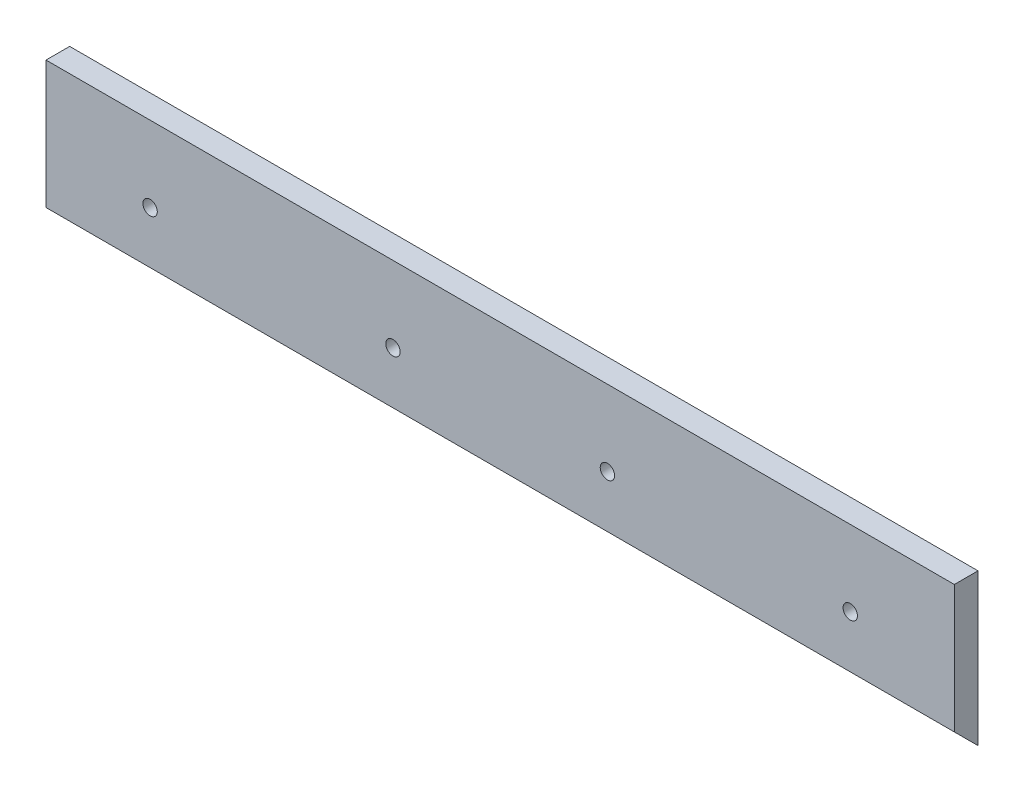
from build123d import *

# Parameters (mm, degrees)
SKETCH1_W               = 609.6
SKETCH1_H               = 101.6
BOSS_EXTRUDE1_DEPTH     = 7.9375
CUT_EXTRUDE2_DEPTH      = 612.764500365
CUT_EXTRUDE2_DEPTH_BACK = 612.764500365
CUT_EXTRUDE3_DEPTH      = 310.411854371
CUT_EXTRUDE3_DEPTH_BACK = 310.411854371
SKETCH4_R               = 4.826
SKETCH4_3_R             = 13.1826
SKETCH4_3_R_2           = 4.826
CUT_EXTRUDE4_DEPTH      = 8.128


with BuildPart() as part:
    # Sketch1 → Boss-Extrude1 (new, symmetric)
    with BuildSketch(Plane.XY):
        Rectangle(SKETCH1_W, SKETCH1_H)
    extrude(amount=BOSS_EXTRUDE1_DEPTH, both=True)

    # Sketch3 → Cut-Extrude2 (cut, two sides: drawn at the far end of the back side and taken through both)
    with BuildSketch(Plane(origin=(304.8, 0, 0), x_dir=(0, 0, -1), z_dir=(1, 0, 0)).offset(-CUT_EXTRUDE2_DEPTH_BACK)):
        Polygon((7.9375, -50.8), (-7.9375, -34.925), (-7.9375, -50.8), align=None)
    extrude(amount=CUT_EXTRUDE2_DEPTH + CUT_EXTRUDE2_DEPTH_BACK, mode=Mode.SUBTRACT)

    # Sketch4 → Cut-Extrude3 (cut, two sides: drawn at the far end of the back side and taken through both)
    with BuildSketch(Plane(origin=(0, 0, -7.9375), x_dir=(-1, 0, 0), z_dir=(0, 0, -1)).offset(-CUT_EXTRUDE3_DEPTH_BACK)):
        with Locations((-234.95, 0)):
            Circle(SKETCH4_R)
        with Locations((-71.966666709, 0)):
            Circle(SKETCH4_R)
        with Locations((71.966666709, 0)):
            Circle(SKETCH4_R)
        with Locations((234.95, 0)):
            Circle(SKETCH4_R)
    extrude(amount=CUT_EXTRUDE3_DEPTH + CUT_EXTRUDE3_DEPTH_BACK, mode=Mode.SUBTRACT)

    # Sketch4_3 → Cut-Extrude4 (cut)
    # profile 1 of 4: a face of its own
    with BuildSketch(Plane(origin=(0, 0, -7.9375), x_dir=(-1, 0, 0), z_dir=(0, 0, -1))):
        with Locations((-234.95, 0)):
            Circle(SKETCH4_3_R)
        with Locations((-234.95, 0)):
            Circle(SKETCH4_3_R_2, mode=Mode.SUBTRACT)
    # profile 2 of 4: a face of its own
    with BuildSketch(Plane(origin=(0, 0, -7.9375), x_dir=(-1, 0, 0), z_dir=(0, 0, -1))):
        with Locations((-71.966666709, 0)):
            Circle(SKETCH4_3_R)
        with Locations((-71.966666709, 0)):
            Circle(SKETCH4_3_R_2, mode=Mode.SUBTRACT)
    # profile 3 of 4: a face of its own
    with BuildSketch(Plane(origin=(0, 0, -7.9375), x_dir=(-1, 0, 0), z_dir=(0, 0, -1))):
        with Locations((234.95, 0)):
            Circle(SKETCH4_3_R)
        with Locations((234.95, 0)):
            Circle(SKETCH4_3_R_2, mode=Mode.SUBTRACT)
    # profile 4 of 4: a face of its own
    with BuildSketch(Plane(origin=(0, 0, -7.9375), x_dir=(-1, 0, 0), z_dir=(0, 0, -1))):
        with Locations((71.966666709, 0)):
            Circle(SKETCH4_3_R)
        with Locations((71.966666709, 0)):
            Circle(SKETCH4_3_R_2, mode=Mode.SUBTRACT)
    extrude(amount=-CUT_EXTRUDE4_DEPTH, mode=Mode.SUBTRACT)


solid = part.part
